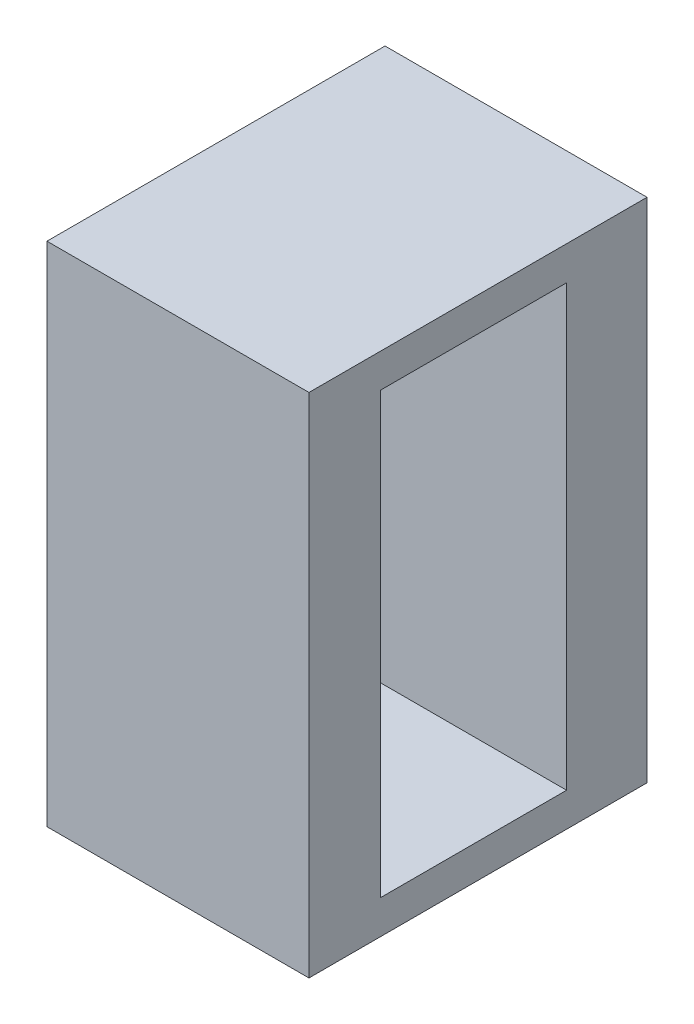
from build123d import *

# Parameters (mm, degrees)
SKETCH_1_W          = 3.1
SKETCH_1_H          = 6
EXTRUDE_1_DEPTH     = 4
SKETCH_2_W          = 2.2
SKETCH_2_H          = 5.2
CUT_EXTRUDE_1_DEPTH = 2.7


with BuildPart() as part:
    # 草图1 → 凸台-拉伸1 (new body)
    with BuildSketch(Plane.XY):
        with Locations((-2.33035, 17.88337)):
            Rectangle(SKETCH_1_W, SKETCH_1_H)
    extrude(amount=EXTRUDE_1_DEPTH)

    # 草图2 → 切除-拉伸1 (cut)
    with BuildSketch(Plane(origin=(-0.78035, 0, 0), x_dir=(0, 0, -1), z_dir=(1, 0, 0))):
        with Locations((-2.052017878, 17.88337)):
            Rectangle(SKETCH_2_W, SKETCH_2_H)
    extrude(amount=-CUT_EXTRUDE_1_DEPTH, mode=Mode.SUBTRACT)


solid = part.part
